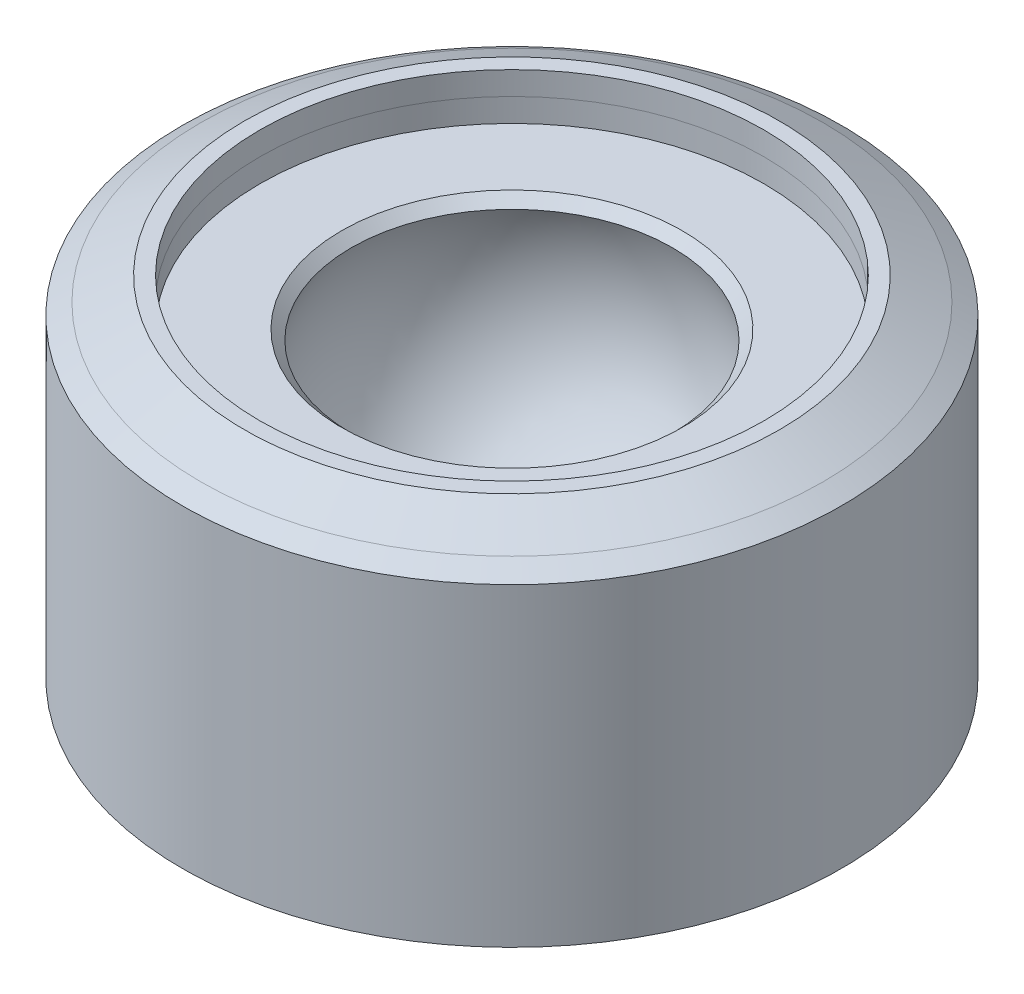
from build123d import *


with BuildPart() as part:
    # Sketch1 → Revolve1 (revolve)
    with BuildSketch(Plane.XY):
        with BuildLine():
            Line((-19.513838733, 23.330040777), (-19.513838733, 26.330040777))
            Line((-19.513838733, 26.330040777), (-21.513838733, 26.330040777))
            Line((-21.513838733, 26.330040777), (-27.138378423, 23.330040777))
            Line((-27.138378423, 23.330040777), (-29.513838733, 21.835217327))
            Line((-29.513838733, 21.835217327), (-29.513838733, -18.669959223))
            Line((-29.513838733, -18.669959223), (12.986161267, -18.669959223))
            Line((12.986161267, -18.669959223), (12.986161267, -12.147726016))
            ThreePointArc((12.986161267, -12.147726016), (-5.743453451, -2.097812317), (-7.724873095, 19.065202805))
            Line((-7.724873095, 19.065202805), (-8.991099708, 20.330040777))
            Line((-8.991099708, 20.330040777), (-19.498450474, 20.330040777))
            Line((-19.498450474, 20.330040777), (-19.513838733, 23.330040777))
        make_face()
    revolve(axis=Axis((12.986161267, -12.147726016, 0), (0, -1, 0)))


solid = part.part
